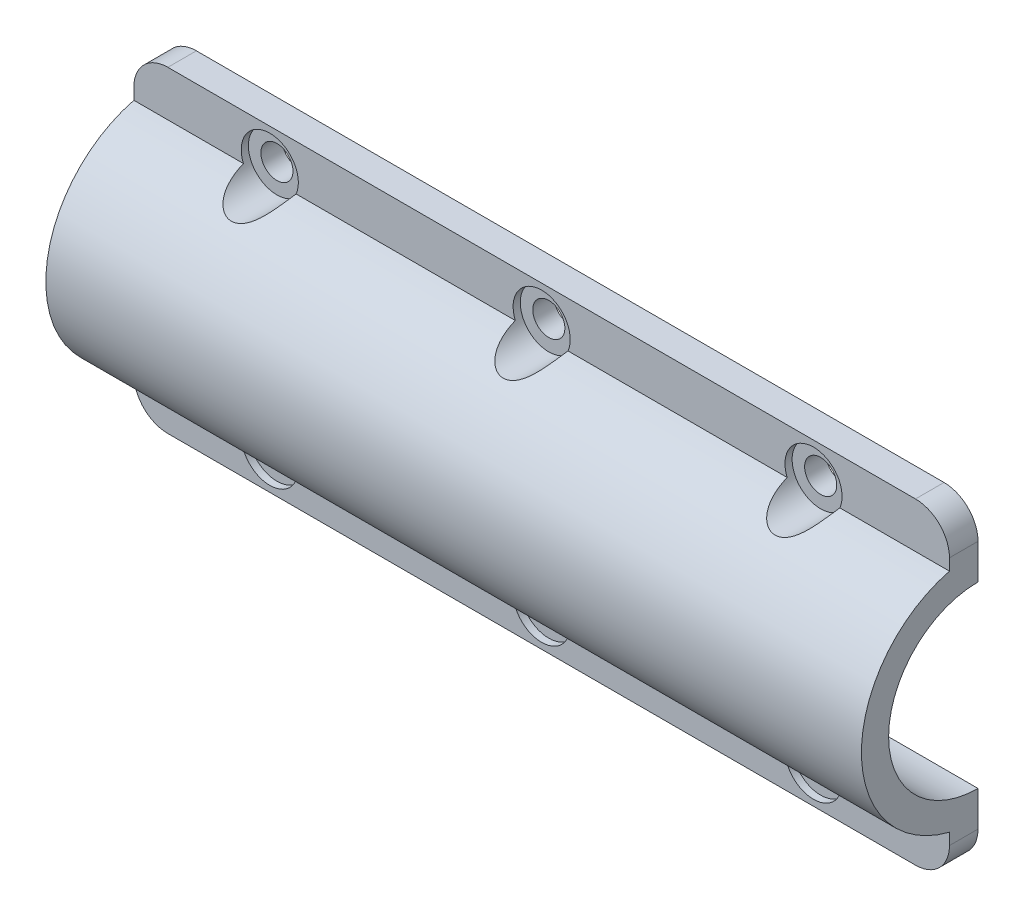
from build123d import *

# Parameters (mm, degrees)
BOSS_EXTRUDE1_DEPTH  = 114.3
CUT_EXTRUDE1_START   = -1
SKETCH2_R            = 4
CUT_EXTRUDE1_DEPTH   = 7.35
M4_CLEARANCE_HOLE1_D = 4.5
FILLET1_R            = 4.7625


with BuildPart() as part:
    # Sketch1 → Boss-Extrude1 (new body)
    with BuildSketch(Plane(origin=(0, 0, 0), x_dir=(0, 0, -1), z_dir=(1, 0, 0))):
        with BuildLine():
            Line((0, 22.225), (-4, 22.225))
            Line((-4, 22.225), (-4, 15.839643355))
            ThreePointArc((-4, 15.839643355), (-2.015394761, 16.212109226), (0, 16.3369))
            Line((0, 16.3369), (0, 17.4625))
            Line((0, 17.4625), (0, 22.225))
        make_face()
        with BuildLine():
            ThreePointArc((0, 16.3369), (-2.015394761, 16.212109226), (-4, 15.839643355))
            ThreePointArc((-4, 15.839643355), (-16.3369, 0), (-4, -15.839643355))
            ThreePointArc((-4, -15.839643355), (-2.015394761, -16.212109226), (0, -16.3369))
            Line((0, -16.3369), (0, -12.5269))
            ThreePointArc((0, -12.5269), (-12.361865073, -2.026700652), (-4, 11.871108778))
            ThreePointArc((-4, 11.871108778), (-2.026700652, 12.361865073), (0, 12.5269))
            Line((0, 12.5269), (0, 16.3369))
        make_face()
        with BuildLine():
            ThreePointArc((0, -16.3369), (-2.015394761, -16.212109226), (-4, -15.839643355))
            Line((-4, -15.839643355), (-4, -22.225))
            Line((-4, -22.225), (0, -22.225))
            Line((0, -22.225), (0, -17.4625))
            Line((0, -17.4625), (0, -16.3369))
        make_face()
    extrude(amount=BOSS_EXTRUDE1_DEPTH)

    # Sketch2 → Cut-Extrude1 (cut)
    with BuildSketch(Plane.XY.offset(4).offset(CUT_EXTRUDE1_START)):
        with Locations((19.05, -17.37595)):
            Circle(SKETCH2_R)
        with Locations((57.15, -17.37595)):
            Circle(SKETCH2_R)
        with Locations((95.25, -17.37595)):
            Circle(SKETCH2_R)
    cut_extrude1 = extrude(amount=CUT_EXTRUDE1_DEPTH, mode=Mode.SUBTRACT)

    # M4 Clearance Hole1 (through all)
    with Locations(Plane.XY.offset(4)):
        with Locations((19.05, -17.37595), (57.15, -17.37595), (95.25, -17.37595)):
            m4_clearance_hole1 = Hole(M4_CLEARANCE_HOLE1_D / 2)

    # Mirror1: Cut-Extrude1, M4 Clearance Hole1 across plane
    add(cut_extrude1.mirror(Plane.ZX), mode=Mode.SUBTRACT)
    add(m4_clearance_hole1.mirror(Plane.ZX), mode=Mode.SUBTRACT)

    # Fillet1
    fillet1_edges = [part.edges().sort_by_distance(p)[0] for p in [
        (0, 22.225, 2),
        (0, -22.225, 2),
        (114.3, -22.225, 2),
        (114.3, 22.225, 2),
    ]]
    fillet(fillet1_edges, radius=FILLET1_R)


solid = part.part
